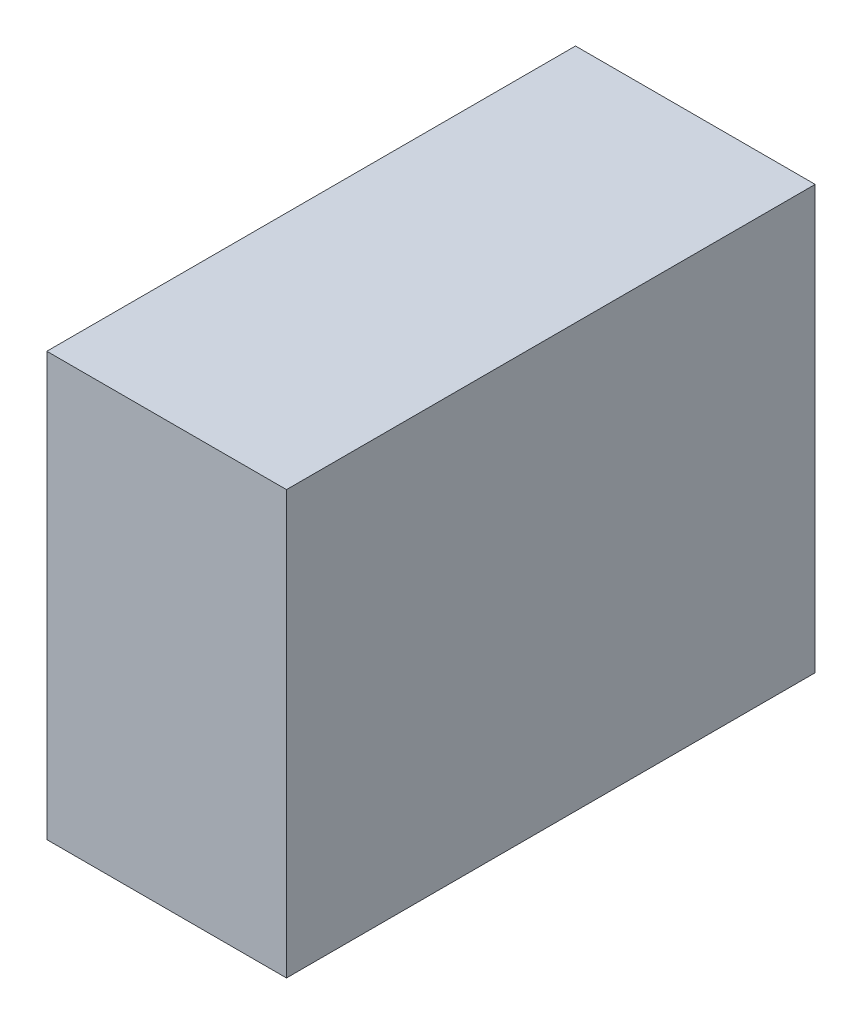
from build123d import *

# Parameters (mm, degrees)
CROQUIS1_W              = 68
CROQUIS1_H              = 120
SALIENTE_EXTRUIR1_DEPTH = 150


with BuildPart() as part:
    # Croquis1 → Saliente-Extruir1 (new body)
    with BuildSketch(Plane.XY):
        with Locations((34, 60)):
            Rectangle(CROQUIS1_W, CROQUIS1_H)
    extrude(amount=SALIENTE_EXTRUIR1_DEPTH)


solid = part.part
